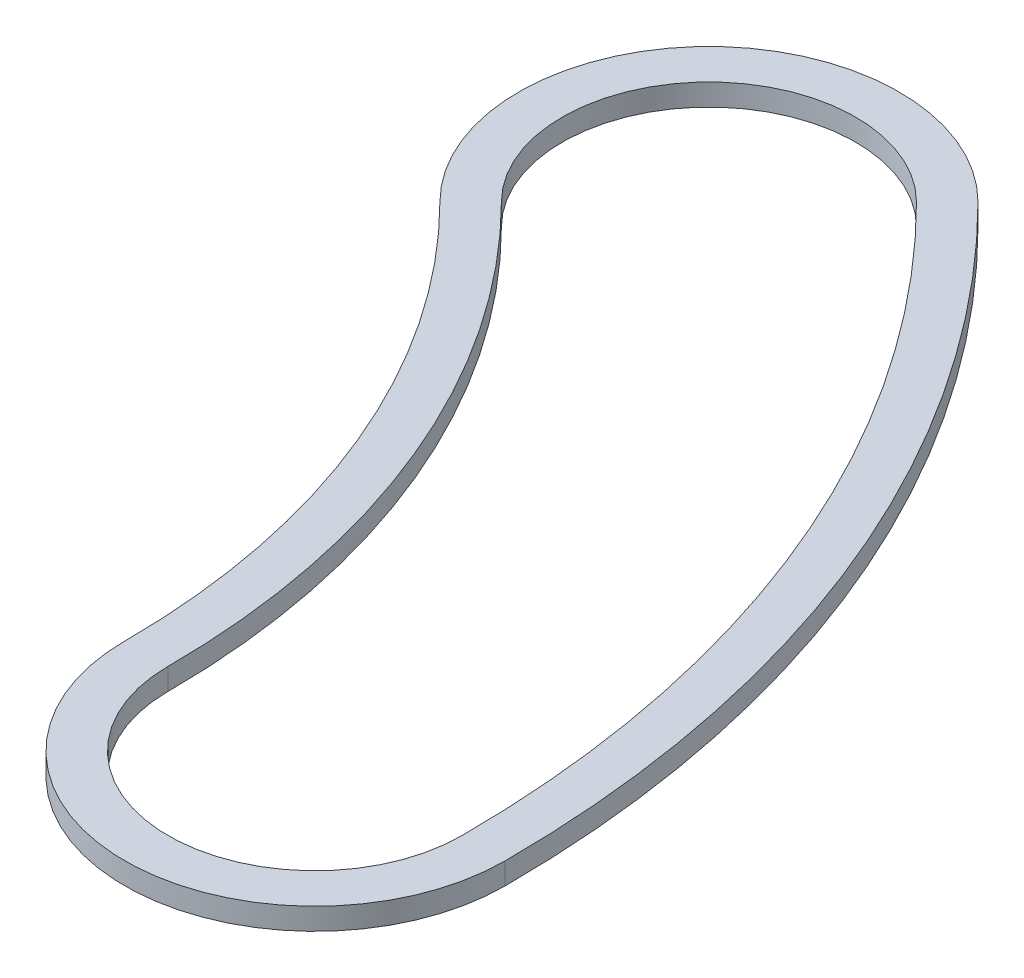
from build123d import *

# Parameters (mm, degrees)
BOSS_EXTRUDE1_DEPTH = 0.508


with BuildPart() as part:
    # Sketch1 → Boss-Extrude1 (new body)
    with BuildSketch(Plane(origin=(0, 0, 0), x_dir=(1, 0, 0), z_dir=(0, 1, 0))):
        with BuildLine():
            ThreePointArc((26.67, 0), (24.639867132, 10.206167141), (18.858537854, 18.858537854))
            ThreePointArc((18.858537854, 18.858537854), (12.572358569, 18.858537854), (12.572358569, 12.572358569))
            ThreePointArc((12.572358569, 12.572358569), (16.426578088, 6.804111427), (17.78, 0))
            ThreePointArc((17.78, 0), (22.225, -4.445), (26.67, 0))
        make_face()
        with BuildLine():
            ThreePointArc((25.654, 0), (23.701205527, 9.817360774), (18.140117365, 18.140117365))
            ThreePointArc((18.140117365, 18.140117365), (13.290779059, 18.140117365), (13.290779059, 13.290779059))
            ThreePointArc((13.290779059, 13.290779059), (17.365239693, 7.192917795), (18.796, 0))
            ThreePointArc((18.796, 0), (22.225, -3.429), (25.654, 0))
        make_face(mode=Mode.SUBTRACT)
    extrude(amount=BOSS_EXTRUDE1_DEPTH)


solid = part.part
